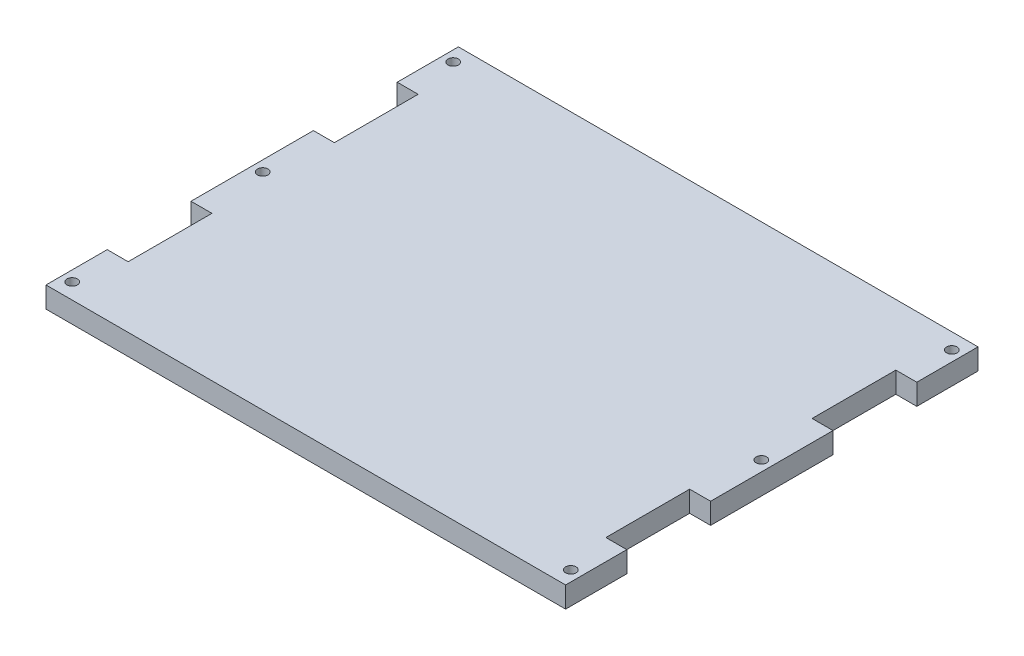
from build123d import *

# Parameters (mm, degrees)
CROQUIS1_W              = 315
CROQUIS1_H              = 250
CROQUIS1_R              = 3.175
SALIENTE_EXTRUIR1_DEPTH = 12.7
CROQUIS2_W              = 12.7
CROQUIS2_H              = 50.8
CORTAR_EXTRUIR1_DEPTH   = 13.7
CROQUIS3_R              = 5
CORTAR_EXTRUIR2_DEPTH   = 1


with BuildPart() as part:
    # Croquis1 → Saliente-Extruir1 (new body)
    with BuildSketch(Plane(origin=(0, 0, 0), x_dir=(1, 0, 0), z_dir=(0, 1, 0))):
        Rectangle(CROQUIS1_W, CROQUIS1_H)
        with Locations((-151.15, -115.475)):
            Circle(CROQUIS1_R, mode=Mode.SUBTRACT)
        with Locations((-151.15, 0)):
            Circle(CROQUIS1_R, mode=Mode.SUBTRACT)
        with Locations((-151.15, 115.475)):
            Circle(CROQUIS1_R, mode=Mode.SUBTRACT)
        with Locations((151.15, 115.475)):
            Circle(CROQUIS1_R, mode=Mode.SUBTRACT)
        with Locations((151.15, 0)):
            Circle(CROQUIS1_R, mode=Mode.SUBTRACT)
        with Locations((151.15, -115.475)):
            Circle(CROQUIS1_R, mode=Mode.SUBTRACT)
    extrude(amount=SALIENTE_EXTRUIR1_DEPTH)

    # Croquis2 → Cortar-Extruir1 (cut, through all)
    with BuildSketch(Plane(origin=(0, 12.7, 0), x_dir=(1, 0, 0), z_dir=(0, 1, 0))):
        with Locations((-151.15, 62.5)):
            Rectangle(CROQUIS2_W, CROQUIS2_H)
        with Locations((-151.15, -62.5)):
            Rectangle(CROQUIS2_W, CROQUIS2_H)
    cortar_extruir1 = extrude(amount=-CORTAR_EXTRUIR1_DEPTH, mode=Mode.SUBTRACT)

    # Simetría1: Cortar-Extruir1 across plane
    add(cortar_extruir1.mirror(Plane(origin=(0, 0, 0), x_dir=(0, 0, 1), z_dir=(1, 0, 0))), mode=Mode.SUBTRACT)

    # Croquis3 → Cortar-Extruir2 (cut)
    with BuildSketch(Plane(origin=(0, 0, 0), x_dir=(-1, 0, 0), z_dir=(0, -1, 0))):
        with Locations((104.5, -63)):
            Circle(CROQUIS3_R)
    extrude(amount=-CORTAR_EXTRUIR2_DEPTH, mode=Mode.SUBTRACT)


solid = part.part
